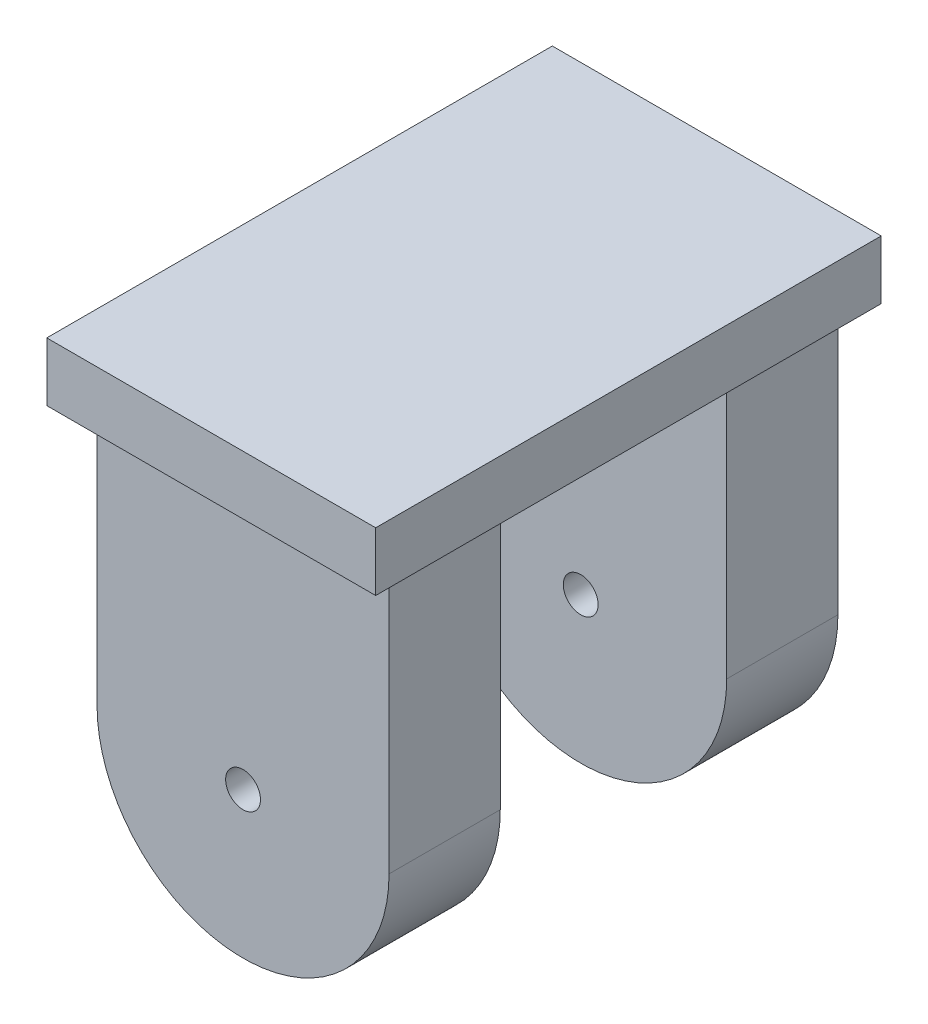
from build123d import *

# Parameters (mm, degrees)
SKETCH4_R           = 5
BOSS_EXTRUDE4_DEPTH = 64.422352731
SKETCH6_W           = 94.412285725
SKETCH6_H           = 145.116249754
BOSS_EXTRUDE5_DEPTH = 16.844705461
SKETCH7_W           = 105.313643584
SKETCH7_H           = 127.479897163
CUT_EXTRUDE1_DEPTH  = 32.5


with BuildPart() as part:
    # Sketch4 → Boss-Extrude4 (new body, symmetric)
    with BuildSketch(Plane.XY):
        with BuildLine():
            Line((-21.492390891, 31.428545296), (-21.492390891, 107.442049888))
            Line((-21.492390891, 107.442049888), (62.333666954, 107.442049888))
            Line((62.333666954, 107.442049888), (62.333666954, 31.428545296))
            ThreePointArc((62.333666954, 31.428545296), (20.420638031, -10.484483627), (-21.492390891, 31.428545296))
        make_face()
        with Locations((20.420638031, 31.428545296)):
            Circle(SKETCH4_R, mode=Mode.SUBTRACT)
    extrude(amount=BOSS_EXTRUDE4_DEPTH, both=True)

    # Sketch6 → Boss-Extrude5 (add)
    with BuildSketch(Plane(origin=(0, 107.442049888, 0), x_dir=(1, 0, 0), z_dir=(0, 1, 0))):
        with Locations((20.027144796, -0.604818135)):
            Rectangle(SKETCH6_W, SKETCH6_H)
    extrude(amount=BOSS_EXTRUDE5_DEPTH)

    # Sketch7 → Cut-Extrude1 (cut, symmetric)
    with BuildSketch(Plane.XY):
        with Locations((20.29997807, 43.702101306)):
            Rectangle(SKETCH7_W, SKETCH7_H)
    extrude(amount=CUT_EXTRUDE1_DEPTH, both=True, mode=Mode.SUBTRACT)


solid = part.part
